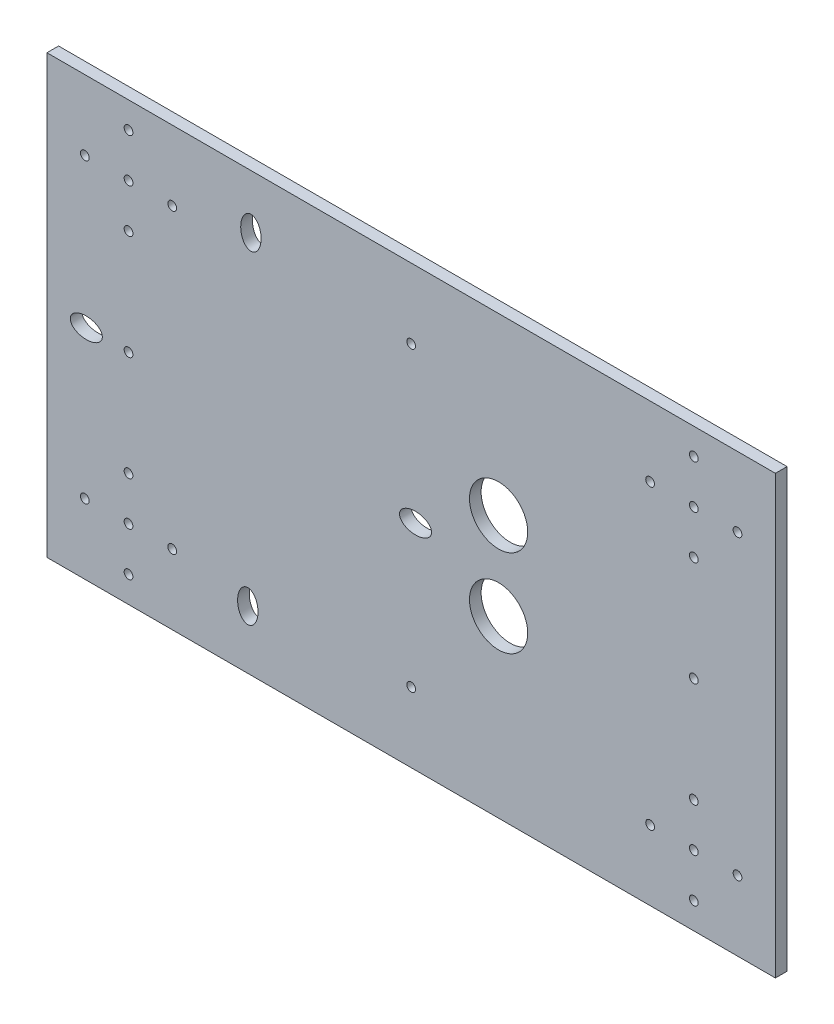
from build123d import *

# Parameters (mm, degrees)
SKETCH1_W           = 250
SKETCH1_H           = 150
SKETCH1_R           = 1.5
SKETCH1_R_2         = 10
SKETCH1_RX          = 5.5
SKETCH1_RY          = 3.5
BOSS_EXTRUDE3_DEPTH = 4


with BuildPart() as part:
    # Sketch1 → Boss-Extrude3 (new body)
    with BuildSketch(Plane.XY):
        with Locations((64.901502586, -41.133333333)):
            Rectangle(SKETCH1_W, SKETCH1_H)
        with Locations((-32.098497414, -92.133333333)):
            Circle(SKETCH1_R, mode=Mode.SUBTRACT)
        with Locations((-17.098497414, -92.133333333)):
            Circle(SKETCH1_R, mode=Mode.SUBTRACT)
        with Locations((-32.098497414, -107.133333333)):
            Circle(SKETCH1_R, mode=Mode.SUBTRACT)
        with Locations((-47.098497414, -92.133333333)):
            Circle(SKETCH1_R, mode=Mode.SUBTRACT)
        with Locations((-32.098497414, -77.133333333)):
            Circle(SKETCH1_R, mode=Mode.SUBTRACT)
        with Locations((176.901502586, -92.133333333)):
            Circle(SKETCH1_R, mode=Mode.SUBTRACT)
        with Locations((161.901502586, -92.133333333)):
            Circle(SKETCH1_R, mode=Mode.SUBTRACT)
        with Locations((161.901502586, -77.133333333)):
            Circle(SKETCH1_R, mode=Mode.SUBTRACT)
        with Locations((146.901502586, -92.133333333)):
            Circle(SKETCH1_R, mode=Mode.SUBTRACT)
        with Locations((161.901502586, -107.133333333)):
            Circle(SKETCH1_R, mode=Mode.SUBTRACT)
        with Locations((176.901502586, 9.866666667)):
            Circle(SKETCH1_R, mode=Mode.SUBTRACT)
        with Locations((161.901502586, 9.866666667)):
            Circle(SKETCH1_R, mode=Mode.SUBTRACT)
        with Locations((161.901502586, 24.866666667)):
            Circle(SKETCH1_R, mode=Mode.SUBTRACT)
        with Locations((146.901502586, 9.866666667)):
            Circle(SKETCH1_R, mode=Mode.SUBTRACT)
        with Locations((161.901502586, -5.133333333)):
            Circle(SKETCH1_R, mode=Mode.SUBTRACT)
        with Locations((-17.098497414, 9.866666667)):
            Circle(SKETCH1_R, mode=Mode.SUBTRACT)
        with Locations((-32.098497414, 9.866666667)):
            Circle(SKETCH1_R, mode=Mode.SUBTRACT)
        with Locations((-32.098497414, 24.866666667)):
            Circle(SKETCH1_R, mode=Mode.SUBTRACT)
        with Locations((-47.098497414, 9.866666667)):
            Circle(SKETCH1_R, mode=Mode.SUBTRACT)
        with Locations((-32.098497414, -5.133333333)):
            Circle(SKETCH1_R, mode=Mode.SUBTRACT)
        with Locations((-32.098497414, -41.133333333)):
            Circle(SKETCH1_R, mode=Mode.SUBTRACT)
        with Locations((161.901502586, -41.133333333)):
            Circle(SKETCH1_R, mode=Mode.SUBTRACT)
        with Locations((64.901502586, 9.866666667)):
            Circle(SKETCH1_R, mode=Mode.SUBTRACT)
        with Locations((64.901502586, -92.133333333)):
            Circle(SKETCH1_R, mode=Mode.SUBTRACT)
        with Locations((94.901502586, -26.133333333)):
            Circle(SKETCH1_R_2, mode=Mode.SUBTRACT)
        with Locations((94.901502586, -56.133333333)):
            Circle(SKETCH1_R_2, mode=Mode.SUBTRACT)
        with Locations((-46.598497414, -41.133333333)):
            Ellipse(SKETCH1_RX, SKETCH1_RY, mode=Mode.SUBTRACT)
        with Locations(Location((9.901502586, 15.366666667), (0, 0, -90))):
            Ellipse(SKETCH1_RX, SKETCH1_RY, mode=Mode.SUBTRACT)
        with Locations(Location((66.401502586, -42.699426362), (0, 0, 180))):
            Ellipse(SKETCH1_RX, SKETCH1_RY, mode=Mode.SUBTRACT)
        with Locations(Location((8.835409557, -96.133333333), (0, 0, -90))):
            Ellipse(SKETCH1_RX, SKETCH1_RY, mode=Mode.SUBTRACT)
    extrude(amount=BOSS_EXTRUDE3_DEPTH)


solid = part.part
